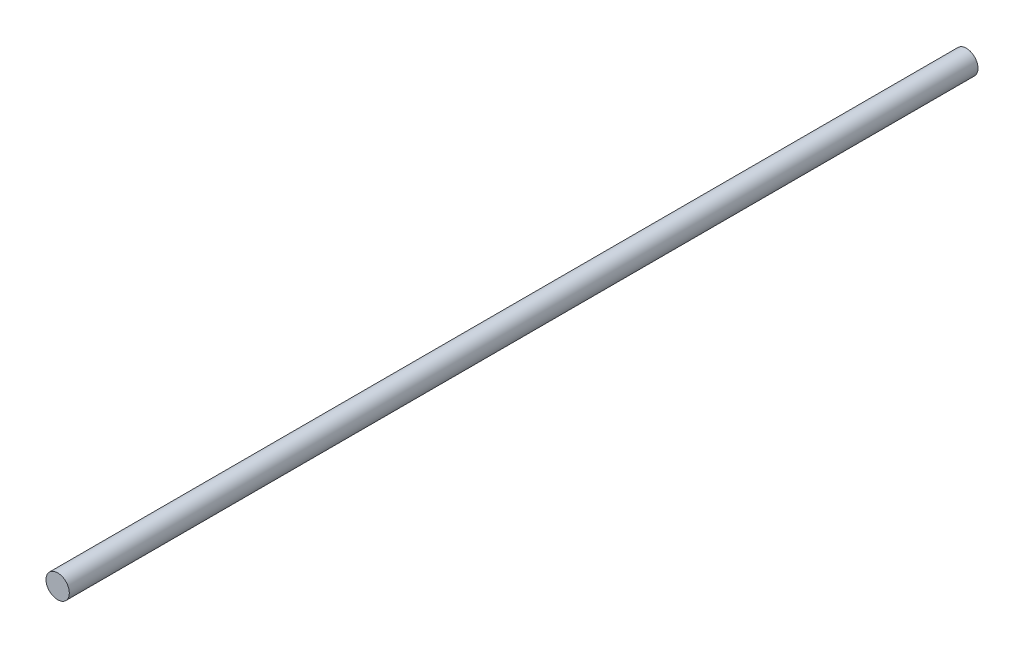
from build123d import *

# Parameters (mm, degrees)
SKETCH1_R           = 4
BOSS_EXTRUDE1_DEPTH = 311.5


with BuildPart() as part:
    # Sketch1 → Boss-Extrude1 (new body)
    with BuildSketch(Plane.XY):
        Circle(SKETCH1_R)
    extrude(amount=BOSS_EXTRUDE1_DEPTH)


solid = part.part
